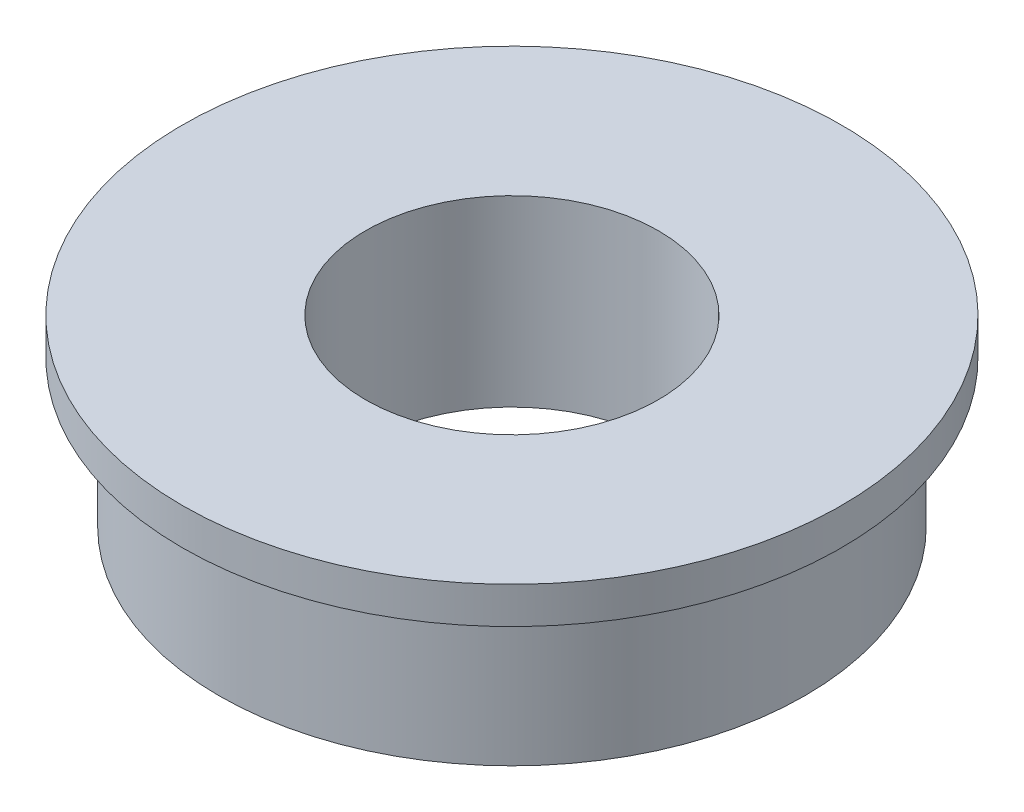
from build123d import *

# Parameters (mm, degrees)
SKETCH_1_R      = 8
SKETCH_1_R_2    = 4
EXTRUDE_1_DEPTH = 4
SKETCH_2_R      = 9
SKETCH_2_R_2    = 4
EXTRUDE_2_DEPTH = 1


with BuildPart() as part:
    # 草图1 → 凸台-拉伸1 (new body)
    with BuildSketch(Plane(origin=(0, 0, 0), x_dir=(1, 0, 0), z_dir=(0, 1, 0))):
        Circle(SKETCH_1_R)
        Circle(SKETCH_1_R_2, mode=Mode.SUBTRACT)
    extrude(amount=EXTRUDE_1_DEPTH)

    # 草图2 → 凸台-拉伸2 (add)
    with BuildSketch(Plane(origin=(0, 4, 0), x_dir=(1, 0, 0), z_dir=(0, 1, 0))):
        Circle(SKETCH_2_R)
        Circle(SKETCH_2_R_2, mode=Mode.SUBTRACT)
    extrude(amount=EXTRUDE_2_DEPTH)


solid = part.part
